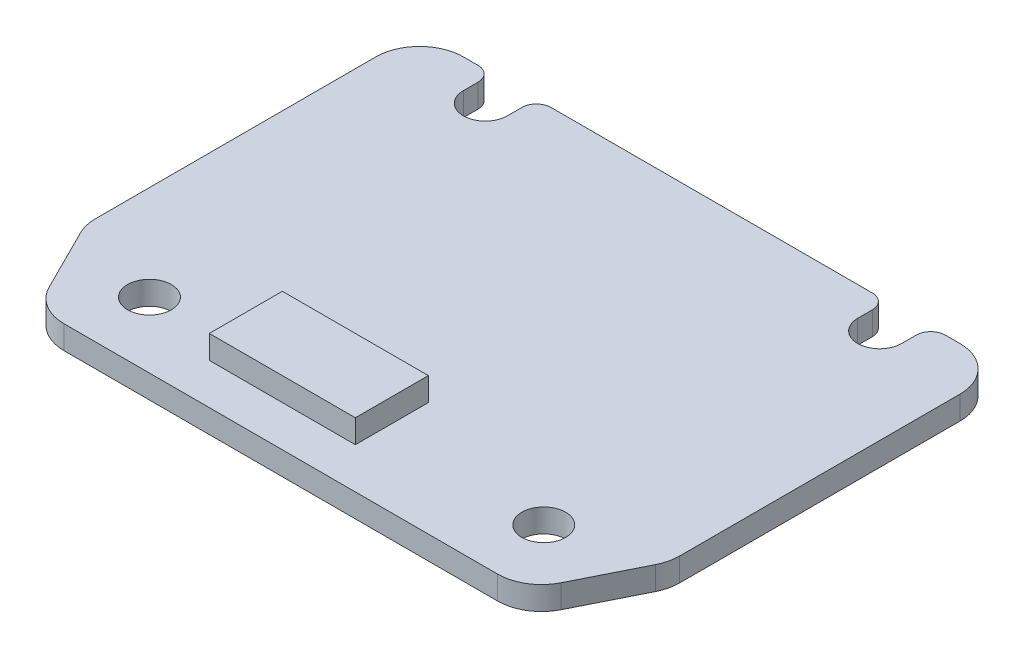
from build123d import *

# Parameters (mm, degrees)
SKETCH1_W                = 40
SKETCH1_H                = 29.5
BOSS_EXTRUDE1_DEPTH      = 1.6
CUT_EXTRUDE4_DEPTH       = 2.6
FILLET1_R                = 3
M2_CLEARANCE_HOLE1_D     = 3
M2_CLEARANCE_HOLE1_DEPTH = 5.2
M2_CLEARANCE_HOLE1_TIP   = 0.901290929
CUT_EXTRUDE1_DEPTH       = 1
CUT_EXTRUDE1_DEPTH_BACK  = 2.6
FILLET2_R                = 1
SKETCH11_W               = 30
SKETCH11_H               = 28.944863729
SKETCH11_R               = 1
CUT_EXTRUDE3_DEPTH       = 0.001
SKETCH13_W               = 10
SKETCH13_H               = 5
BOSS_EXTRUDE2_DEPTH      = 1.6


with BuildPart() as part:
    # Sketch1 → Boss-Extrude1 (new body)
    with BuildSketch(Plane(origin=(0, 0, 0), x_dir=(1, 0, 0), z_dir=(0, 1, 0))):
        Rectangle(SKETCH1_W, SKETCH1_H)
    extrude(amount=BOSS_EXTRUDE1_DEPTH)

    # Sketch12 → Cut-Extrude4 (cut, through all)
    with BuildSketch(Plane(origin=(0, 1.6, 0), x_dir=(1, 0, 0), z_dir=(0, 1, 0))):
        Polygon((-16.7, -14.75), (-20, -8.15), (-20, -14.75), align=None)
        Polygon((16.7, -14.75), (20, -8.15), (20, -14.75), align=None)
    extrude(amount=-CUT_EXTRUDE4_DEPTH, mode=Mode.SUBTRACT)

    # Fillet1
    fillet1_edges = [part.edges().sort_by_distance(p)[0] for p in [
        (-16.7, 0.8, 14.75),
        (-20, 0.8, 8.15),
        (16.7, 0.8, 14.75),
        (20, 0.8, 8.15),
        (-20, 0.8, -14.75),
        (20, 0.8, -14.75),
    ]]
    fillet(fillet1_edges, radius=FILLET1_R)

    # M2 Clearance Hole1
    with Locations(Plane(origin=(0, 1.6, 0), x_dir=(1, 0, 0), z_dir=(0, 1, 0))):
        with Locations((-13.5, 12.75), (13.5, 12.75), (13.5, -10.25), (-13.5, -10.25)):
            Hole(M2_CLEARANCE_HOLE1_D / 2, depth=M2_CLEARANCE_HOLE1_DEPTH)
            with Locations((0, 0, -(M2_CLEARANCE_HOLE1_DEPTH + M2_CLEARANCE_HOLE1_TIP / 2))):  # 118° drill point
                Cone(0, M2_CLEARANCE_HOLE1_D / 2, M2_CLEARANCE_HOLE1_TIP, mode=Mode.SUBTRACT)

    # Sketch5 → Cut-Extrude1 (cut, two sides)
    with BuildSketch(Plane(origin=(0, 1.6, 0), x_dir=(1, 0, 0), z_dir=(0, 1, 0))) as cut_extrude1_sk:
        with BuildLine():
            Line((-15, 12.75), (-15, 19.75))
            ThreePointArc((-15, 19.75), (-13.5, 21.25), (-12, 19.75))
            Line((-12, 19.75), (-12, 12.75))
            ThreePointArc((-12, 12.75), (-13.5, 11.25), (-15, 12.75))
        make_face()
        with BuildLine():
            Line((15, 12.75), (15, 19.75))
            ThreePointArc((15, 19.75), (13.5, 21.25), (12, 19.75))
            Line((12, 19.75), (12, 12.75))
            ThreePointArc((12, 12.75), (13.5, 11.25), (15, 12.75))
        make_face()
    extrude(amount=CUT_EXTRUDE1_DEPTH, mode=Mode.SUBTRACT)
    extrude(cut_extrude1_sk.sketch, amount=-CUT_EXTRUDE1_DEPTH_BACK, mode=Mode.SUBTRACT)

    # Fillet2
    fillet2_edges = [part.edges().sort_by_distance(p)[0] for p in [
        (-15, 0.8, -14.75),
        (-12, 0.8, -14.75),
        (12, 0.8, -14.75),
        (15, 0.8, -14.75),
    ]]
    fillet(fillet2_edges, radius=FILLET2_R)

    # Sketch11 → Cut-Extrude3 (cut)
    with BuildSketch(Plane.XZ):
        with Locations((0, -0.277568136)):
            Rectangle(SKETCH11_W, SKETCH11_H)
        with Locations((13.5, -12.75)):
            Circle(SKETCH11_R, mode=Mode.SUBTRACT)
        with Locations((13.5, 10.25)):
            Circle(SKETCH11_R, mode=Mode.SUBTRACT)
        with Locations((-13.5, -12.75)):
            Circle(SKETCH11_R, mode=Mode.SUBTRACT)
        with Locations((-13.5, 10.25)):
            Circle(SKETCH11_R, mode=Mode.SUBTRACT)
        with BuildLine():
            Line((-10, 11.694863729), (10, 11.694863729))
            ThreePointArc((10, 11.694863729), (11.434632325, 11.088706998), (12, 9.637516011))
            Line((12, 9.637516011), (12, -9.74800182))
            add(Edge.make_bspline(
                [(10, -11.748801092), (12, -11.748801092), (12, -9.74800182)],
                knots=[3.141592654, 3.141592654, 3.141592654, 4.71238898, 4.71238898, 4.71238898], degree=2, weights=[1, 0.707106781, 1]))
            Line((10, -11.748801092), (-10, -11.748801092))
            add(Edge.make_bspline(
                [(-12, -9.74800182), (-12, -11.748801092), (-10, -11.748801092)],
                knots=[1.570796327, 1.570796327, 1.570796327, 3.141592654, 3.141592654, 3.141592654], degree=2, weights=[1, 0.707106781, 1]))
            Line((-12, -9.74800182), (-12, 9.750612903))
            ThreePointArc((-12, 9.750612903), (-11.394642541, 11.128696782), (-10, 11.694863729))
        make_face(mode=Mode.SUBTRACT)
    extrude(amount=-CUT_EXTRUDE3_DEPTH, mode=Mode.SUBTRACT)


with BuildPart() as body_2:
    # Sketch13 → Boss-Extrude2 (new body)
    with BuildSketch(Plane(origin=(0, 1.6, 0), x_dir=(1, 0, 0), z_dir=(0, 1, 0))):
        with Locations((-2.7, -9.45)):
            Rectangle(SKETCH13_W, SKETCH13_H)
    extrude(amount=BOSS_EXTRUDE2_DEPTH)


solid = Compound([part.part, body_2.part])
